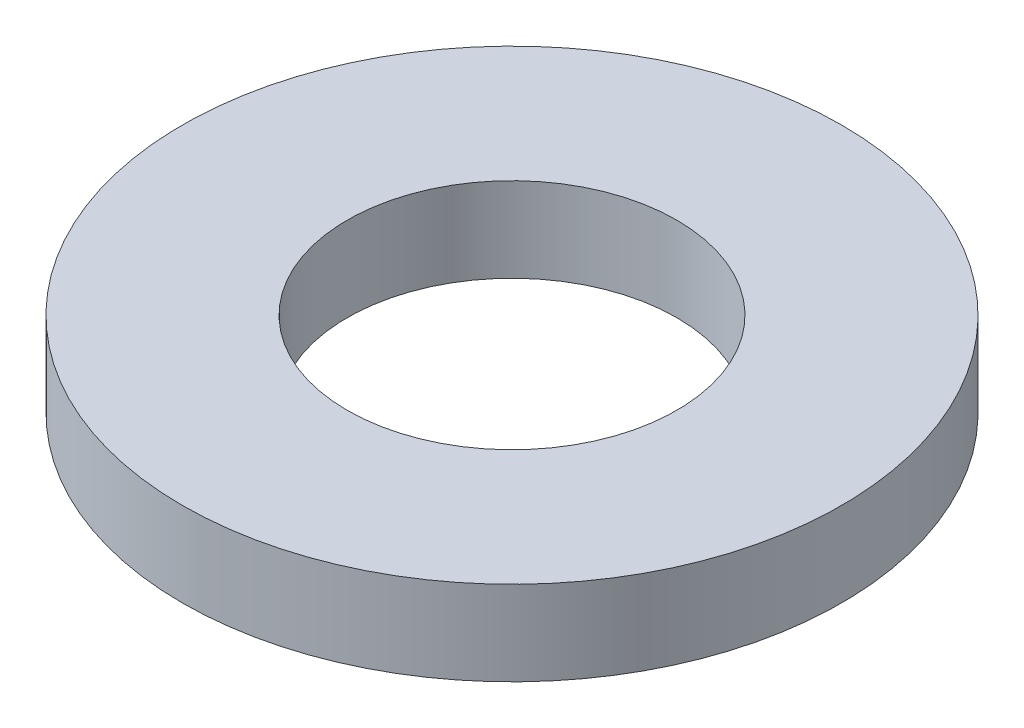
from build123d import *

# Parameters (mm, degrees)
SKETCH1_R           = 3.9624
BOSS_EXTRUDE1_DEPTH = 1.016
SKETCH5_R           = 1.9812
CUT_EXTRUDE1_DEPTH  = 2.016


with BuildPart() as part:
    # Sketch1 → Boss-Extrude1 (new body)
    with BuildSketch(Plane(origin=(0, 0, 0), x_dir=(1, 0, 0), z_dir=(0, 1, 0))):
        Circle(SKETCH1_R)
    extrude(amount=BOSS_EXTRUDE1_DEPTH)

    # Sketch5 → Cut-Extrude1 (cut, through all)
    with BuildSketch(Plane(origin=(0, 1.016, 0), x_dir=(-1, 0, 0), z_dir=(0, 1, 0))):
        Circle(SKETCH5_R)
    extrude(amount=-CUT_EXTRUDE1_DEPTH, mode=Mode.SUBTRACT)


solid = part.part
